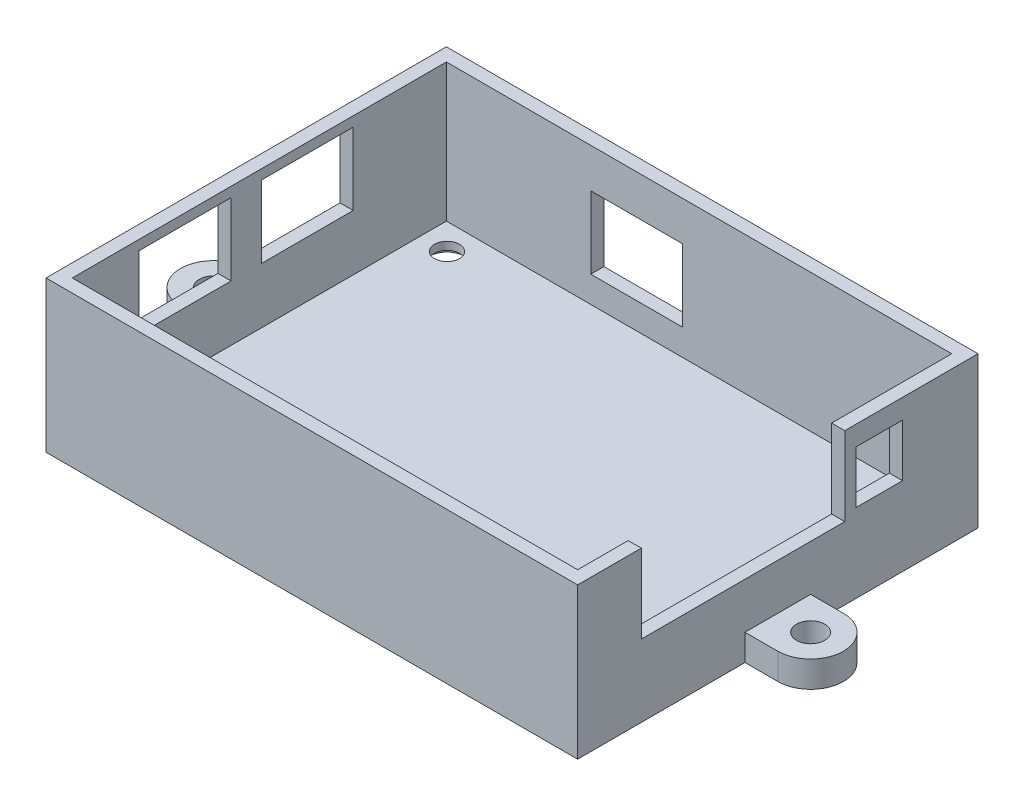
from build123d import *

# Parameters (mm, degrees)
SKETCH_1_W          = 81
SKETCH_1_H          = 61
EXTRUDE_1_DEPTH     = 23
SHELL_1_T           = -2
SKETCH_2_R          = 2.15
EXTRUDE_3_DEPTH     = 4
SKETCH_3_R          = 1.9
CUT_EXTRUDE_1_DEPTH = 2
SKETCH_4_R          = 2.7
SKETCH_4_R_2        = 1.9
CUT_EXTRUDE_2_DEPTH = 0.8
SKETCH_5_W          = 31
SKETCH_5_H          = 12
SKETCH_5_W_2        = 7.1
SKETCH_5_H_2        = 8
CUT_EXTRUDE_3_DEPTH = 2
SKETCH_6_W          = 14
SKETCH_6_H          = 11
CUT_EXTRUDE_4_DEPTH = 2
SKETCH_7_W          = 14
SKETCH_7_H          = 11
CUT_EXTRUDE_5_DEPTH = 2


with BuildPart() as part:
    # 草图1 → 凸台-拉伸1 (new body)
    with BuildSketch(Plane(origin=(0, 0, 0), x_dir=(1, 0, 0), z_dir=(0, 1, 0))):
        Rectangle(SKETCH_1_W, SKETCH_1_H)
    extrude(amount=EXTRUDE_1_DEPTH)

    # 抽壳1
    shell_1_openings = [part.faces().sort_by_distance(p)[0] for p in [
        (0, 23, 0),
    ]]
    offset(amount=SHELL_1_T, openings=shell_1_openings, kind=Kind.INTERSECTION)

    # 草图2 → 凸台-拉伸3 (add)
    with BuildSketch(Plane.XZ):
        with BuildLine():
            Line((-45.5, 5), (-40.5, 5))
            Line((-40.5, 5), (-40.5, -5))
            Line((-40.5, -5), (-45.5, -5))
            ThreePointArc((-45.5, -5), (-50.5, 0), (-45.5, 5))
        make_face()
        with Locations((-45.5, 0)):
            Circle(SKETCH_2_R, mode=Mode.SUBTRACT)
        with BuildLine():
            Line((40.5, -5), (45.5, -5))
            ThreePointArc((45.5, -5), (50.5, 0), (45.5, 5))
            Line((45.5, 5), (40.5, 5))
            Line((40.5, 5), (40.5, -5))
        make_face()
        with Locations((45.5, 0)):
            Circle(SKETCH_2_R, mode=Mode.SUBTRACT)
    extrude(amount=-EXTRUDE_3_DEPTH)

    # 草图3 → 切除-拉伸1 (cut)
    with BuildSketch(Plane(origin=(0, 0, 0), x_dir=(1, 0, 0), z_dir=(0, 1, 0))):
        with Locations((-34.45, -24.55)):
            Circle(SKETCH_3_R)
        with Locations((-34.45, 24.55)):
            Circle(SKETCH_3_R)
        with Locations((34.45, 24.55)):
            Circle(SKETCH_3_R)
        with Locations((34.45, -24.55)):
            Circle(SKETCH_3_R)
    extrude(amount=CUT_EXTRUDE_1_DEPTH, mode=Mode.SUBTRACT)

    # 草图4 → 切除-拉伸2 (cut)
    with BuildSketch(Plane(origin=(0, 0, 0), x_dir=(1, 0, 0), z_dir=(0, 1, 0))):
        with Locations((-34.45, -24.55)):
            Circle(SKETCH_4_R)
        with Locations((-34.45, -24.55)):
            Circle(SKETCH_4_R_2, mode=Mode.SUBTRACT)
        with Locations((-34.45, 24.55)):
            Circle(SKETCH_4_R)
        with Locations((-34.45, 24.55)):
            Circle(SKETCH_4_R_2, mode=Mode.SUBTRACT)
        with Locations((34.45, 24.55)):
            Circle(SKETCH_4_R)
        with Locations((34.45, 24.55)):
            Circle(SKETCH_4_R_2, mode=Mode.SUBTRACT)
        with Locations((34.45, -24.55)):
            Circle(SKETCH_4_R)
        with Locations((34.45, -24.55)):
            Circle(SKETCH_4_R_2, mode=Mode.SUBTRACT)
    extrude(amount=CUT_EXTRUDE_2_DEPTH, mode=Mode.SUBTRACT)

    # 草图5 → 切除-拉伸3 (cut)
    with BuildSketch(Plane(origin=(40.5, 0, 0), x_dir=(0, 0, -1), z_dir=(1, 0, 0))):
        with Locations((-5.3, 17)):
            Rectangle(SKETCH_5_W, SKETCH_5_H)
        with Locations((15.45, 16)):
            Rectangle(SKETCH_5_W_2, SKETCH_5_H_2)
    extrude(amount=-CUT_EXTRUDE_3_DEPTH, mode=Mode.SUBTRACT)

    # 草图6 → 切除-拉伸4 (cut)
    with BuildSketch(Plane(origin=(0, 0, -30.5), x_dir=(-1, 0, 0), z_dir=(0, 0, -1))):
        with Locations((9.5, 11.5)):
            Rectangle(SKETCH_6_W, SKETCH_6_H)
    extrude(amount=-CUT_EXTRUDE_4_DEPTH, mode=Mode.SUBTRACT)

    # 草图7 → 切除-拉伸5 (cut)
    with BuildSketch(Plane.ZY.offset(40.5)):
        with Locations((11.3, 16)):
            Rectangle(SKETCH_7_W, SKETCH_7_H)
        with Locations((-7.3, 16)):
            Rectangle(SKETCH_7_W, SKETCH_7_H)
    extrude(amount=-CUT_EXTRUDE_5_DEPTH, mode=Mode.SUBTRACT)


solid = part.part
